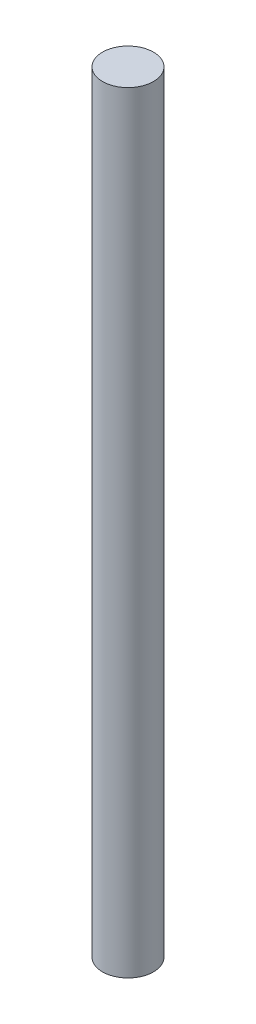
from build123d import *

# Parameters (mm, degrees)
SKETCH1_R           = 3.9
BOSS_EXTRUDE1_DEPTH = 118


with BuildPart() as part:
    # Sketch1 → Boss-Extrude1 (new body)
    with BuildSketch(Plane(origin=(0, 0, 0), x_dir=(1, 0, 0), z_dir=(0, 1, 0))):
        Circle(SKETCH1_R)
    extrude(amount=BOSS_EXTRUDE1_DEPTH)


solid = part.part
